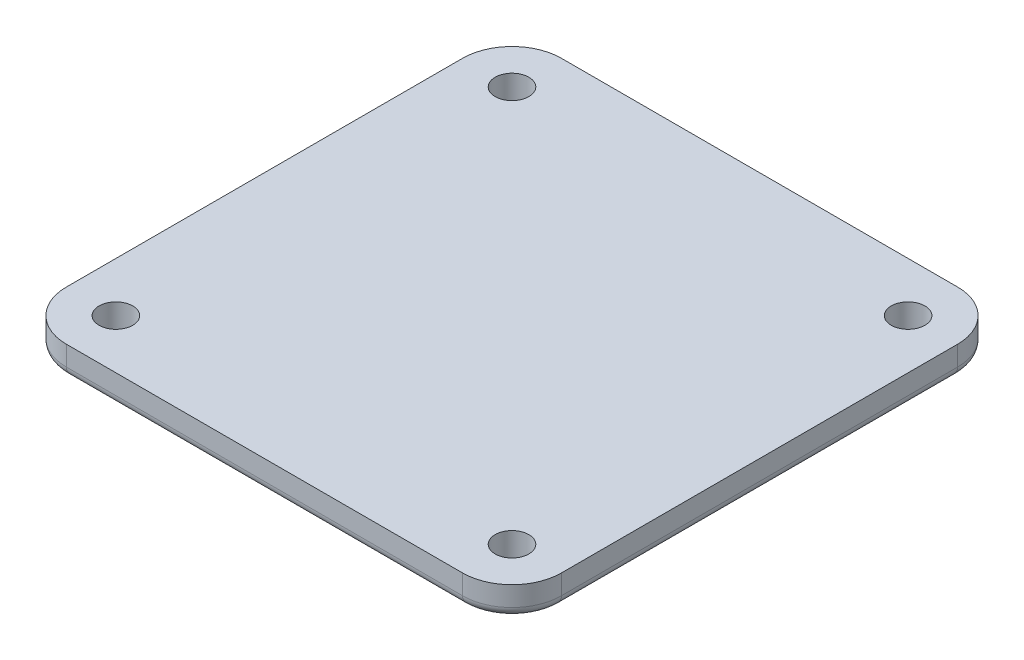
from build123d import *

# Parameters (mm, degrees)
SKETCH1_R           = 1.7
BOSS_EXTRUDE1_DEPTH = 3
FILLET1_R           = 1


with BuildPart() as part:
    # Sketch1 → Boss-Extrude1 (new body)
    with BuildSketch(Plane.XZ.offset(4)):
        with BuildLine():
            Line((-20, -25), (20, -25))
            ThreePointArc((20, -25), (23.535533906, -23.535533906), (25, -20))
            Line((25, -20), (25, 20))
            ThreePointArc((25, 20), (23.535533906, 23.535533906), (20, 25))
            Line((20, 25), (-20, 25))
            ThreePointArc((-20, 25), (-23.535533906, 23.535533906), (-25, 20))
            Line((-25, 20), (-25, -20))
            ThreePointArc((-25, -20), (-23.535533906, -23.535533906), (-20, -25))
        make_face()
        with Locations((-20, 20)):
            Circle(SKETCH1_R, mode=Mode.SUBTRACT)
        with Locations((20, 20)):
            Circle(SKETCH1_R, mode=Mode.SUBTRACT)
        with Locations((-20, -20)):
            Circle(SKETCH1_R, mode=Mode.SUBTRACT)
        with Locations((20, -20)):
            Circle(SKETCH1_R, mode=Mode.SUBTRACT)
    extrude(amount=BOSS_EXTRUDE1_DEPTH)

    # Fillet1
    fillet1_edges = [part.edges().sort_by_distance(p)[0] for p in [
        (23.535533906, -7, -23.535533906),
        (25, -7, 0),
        (23.535533906, -7, 23.535533906),
        (0, -7, 25),
        (-23.535533906, -7, 23.535533906),
        (-25, -7, 0),
        (-23.535533906, -7, -23.535533906),
        (0, -7, -25),
    ]]
    fillet(fillet1_edges, radius=FILLET1_R)


solid = part.part
